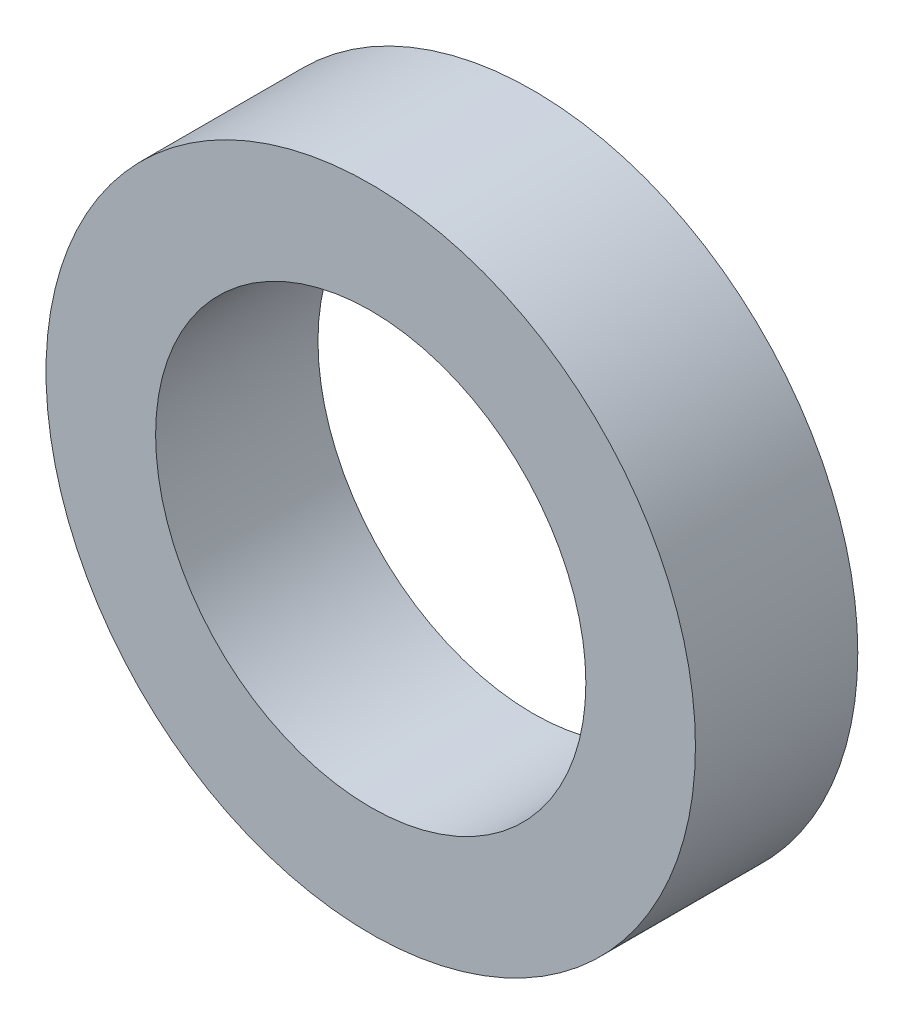
from build123d import *

# Parameters (mm, degrees)
SKETCH1_R           = 4
SKETCH1_R_2         = 2.65
EXTRUDE1_DEPTH      = 1
EXTRUDE1_DEPTH_BACK = 1


with BuildPart() as part:
    # Sketch1 → Extrude1 (new body, two sides)
    with BuildSketch(Plane.XY) as extrude1_sk:
        Circle(SKETCH1_R)
        Circle(SKETCH1_R_2, mode=Mode.SUBTRACT)
    extrude(amount=EXTRUDE1_DEPTH)
    extrude(extrude1_sk.sketch, amount=-EXTRUDE1_DEPTH_BACK)


solid = part.part
